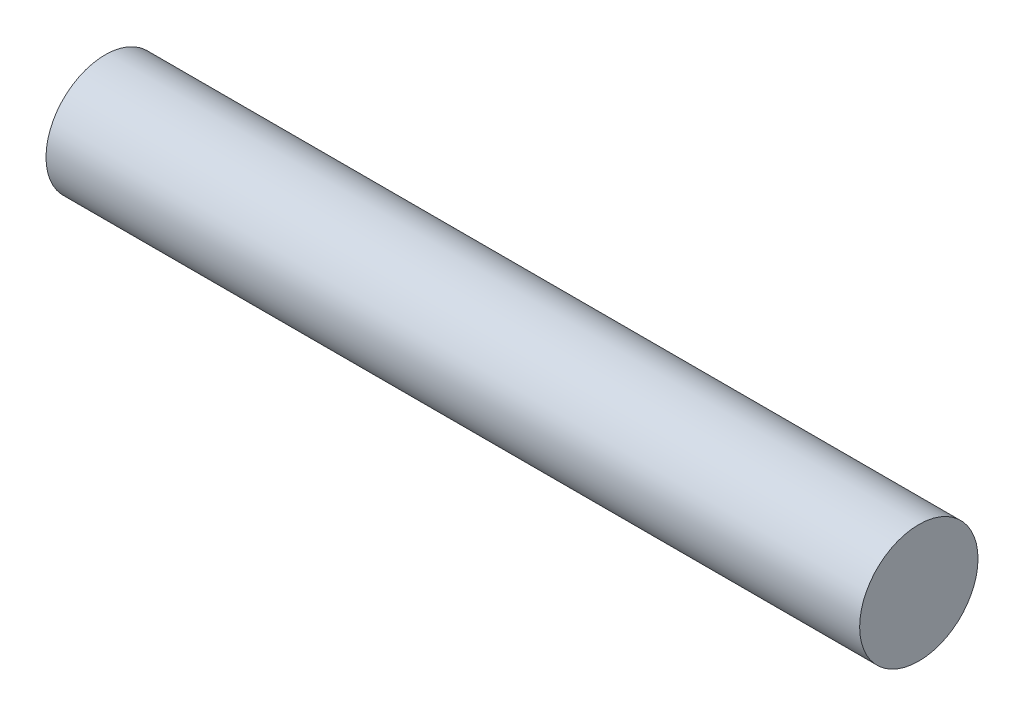
from build123d import *

# Parameters (mm, degrees)
SKETCH1_R           = 3
BOSS_EXTRUDE1_DEPTH = 36.75
SKETCH3_R           = 3
BOSS_EXTRUDE2_DEPTH = 4.5


with BuildPart() as part:
    # Sketch1 → Boss-Extrude1 (new body)
    with BuildSketch(Plane(origin=(0, 0, 0), x_dir=(0, 0, -1), z_dir=(1, 0, 0))):
        Circle(SKETCH1_R)
    extrude(amount=BOSS_EXTRUDE1_DEPTH)

    # Sketch3 → Boss-Extrude2 (add)
    with BuildSketch(Plane.ZY):
        Circle(SKETCH3_R)
    extrude(amount=BOSS_EXTRUDE2_DEPTH)


solid = part.part
